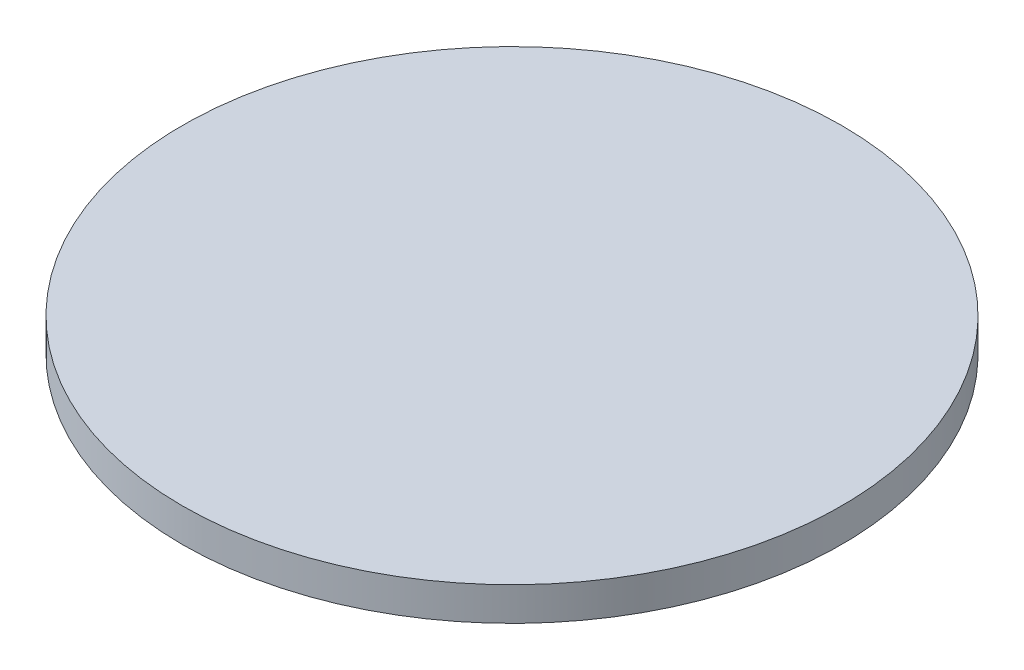
from build123d import *

# Parameters (mm, degrees)
SKIZZE1_R                       = 59
AUFSATZ_LINEAR_AUSTRAGEN1_DEPTH = 6
SKIZZE1_3_R                     = 6
AUFSATZ_LINEAR_AUSTRAGEN2_DEPTH = 2
AUFSATZ_LINEAR_AUSTRAGEN2_DRAFT = -30
SKIZZE2_R                       = 4.262826076
SCHNITT_LINEAR_AUSTRAGEN1_DEPTH = 0.5
SCHNITT_LINEAR_AUSTRAGEN1_DRAFT = -45


with BuildPart() as part:
    # Skizze1 → Aufsatz-Linear austragen1 (new body)
    with BuildSketch(Plane(origin=(0, 0, 0), x_dir=(1, 0, 0), z_dir=(0, 1, 0))):
        Circle(SKIZZE1_R)
    extrude(amount=AUFSATZ_LINEAR_AUSTRAGEN1_DEPTH)


with BuildPart() as aufsatz_linear_austragen2_tool:
    # Skizze1_3 → Aufsatz-Linear austragen2 (with draft: the straight prism first)
    with BuildSketch(Plane(origin=(0, 0, 0), x_dir=(1, 0, 0), z_dir=(0, 1, 0))):
        Circle(SKIZZE1_3_R)
    extrude(amount=-AUFSATZ_LINEAR_AUSTRAGEN2_DEPTH)
    # Aufsatz-Linear austragen2: the draft: its side faces are tilted about the plane it starts from
    aufsatz_linear_austragen2_sides = [aufsatz_linear_austragen2_tool.faces().sort_by_distance(p)[0] for p in [
        (-6, -1, 0),
    ]]
    draft(aufsatz_linear_austragen2_sides, Plane(origin=(0, 0, 0), x_dir=(1, 0, 0), z_dir=(0, 1, 0)), AUFSATZ_LINEAR_AUSTRAGEN2_DRAFT)


with BuildPart() as part_1:
    add(part.part)

    # Aufsatz-Linear austragen2: add aufsatz_linear_austragen2_tool
    add(aufsatz_linear_austragen2_tool.part)


with BuildPart() as schnitt_linear_austragen1_tool:
    # Skizze2 → Schnitt-Linear austragen1 (with draft: the straight prism first)
    with BuildSketch(Plane.XZ.offset(2)):
        Circle(SKIZZE2_R)
    extrude(amount=-SCHNITT_LINEAR_AUSTRAGEN1_DEPTH)
    # Schnitt-Linear austragen1: the draft: its side faces are tilted about the plane it starts from
    schnitt_linear_austragen1_sides = [schnitt_linear_austragen1_tool.faces().sort_by_distance(p)[0] for p in [
        (-4.262826076, -1.75, 0),
    ]]
    draft(schnitt_linear_austragen1_sides, Plane.XZ.offset(2), SCHNITT_LINEAR_AUSTRAGEN1_DRAFT)


with BuildPart() as part_2:
    add(part_1.part)

    # Schnitt-Linear austragen1: cut by schnitt_linear_austragen1_tool
    add(schnitt_linear_austragen1_tool.part, mode=Mode.SUBTRACT)


solid = part_2.part
